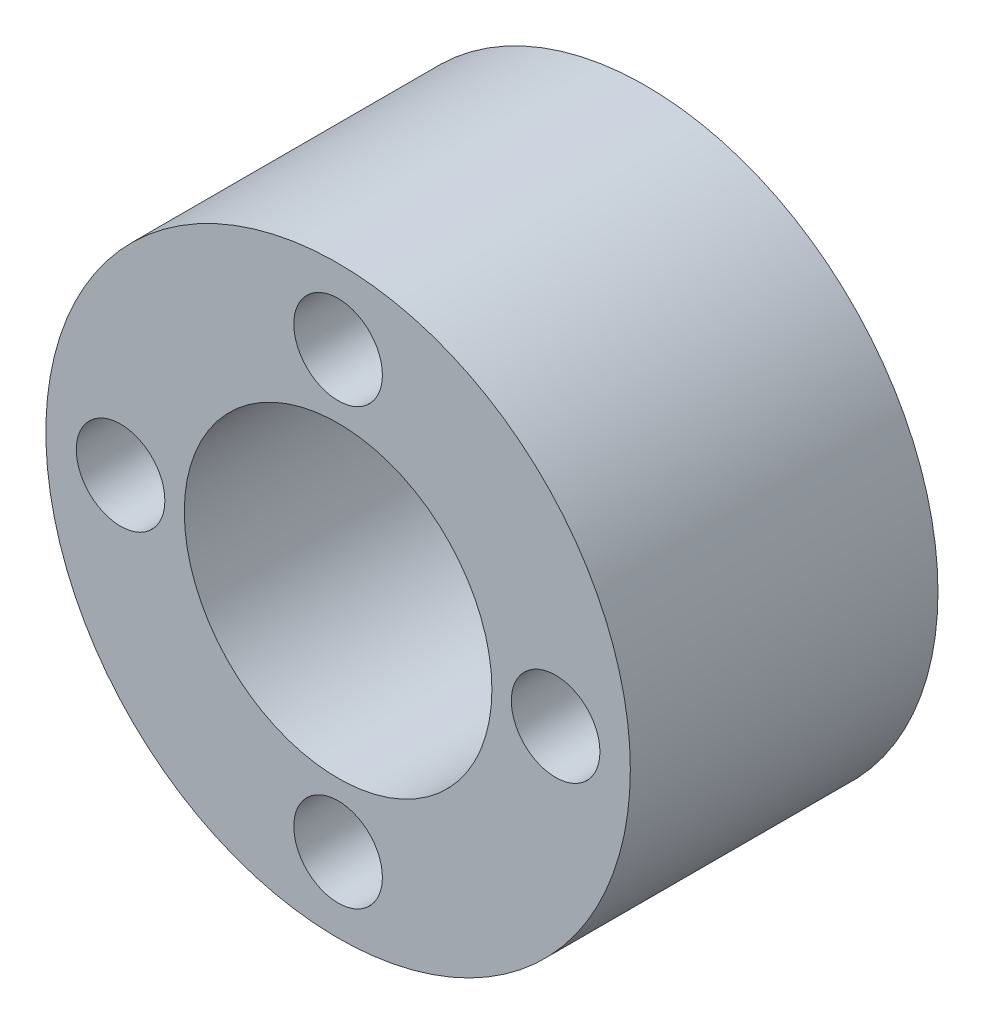
from build123d import *

# Parameters (mm, degrees)
SKETCH1_R           = 12.065
SKETCH1_R_2         = 6.35
SKETCH1_R_3         = 1.8288
BOSS_EXTRUDE1_DEPTH = 12.7


with BuildPart() as part:
    # Sketch1 → Boss-Extrude1 (new body)
    with BuildSketch(Plane.XY):
        Circle(SKETCH1_R)
        Circle(SKETCH1_R_2, mode=Mode.SUBTRACT)
        with Locations((-8.980256121, 0)):
            Circle(SKETCH1_R_3, mode=Mode.SUBTRACT)
        with Locations((8.980256121, 0)):
            Circle(SKETCH1_R_3, mode=Mode.SUBTRACT)
        with Locations((0, 8.980256121)):
            Circle(SKETCH1_R_3, mode=Mode.SUBTRACT)
        with Locations((0, -8.980256121)):
            Circle(SKETCH1_R_3, mode=Mode.SUBTRACT)
    extrude(amount=BOSS_EXTRUDE1_DEPTH)


solid = part.part
